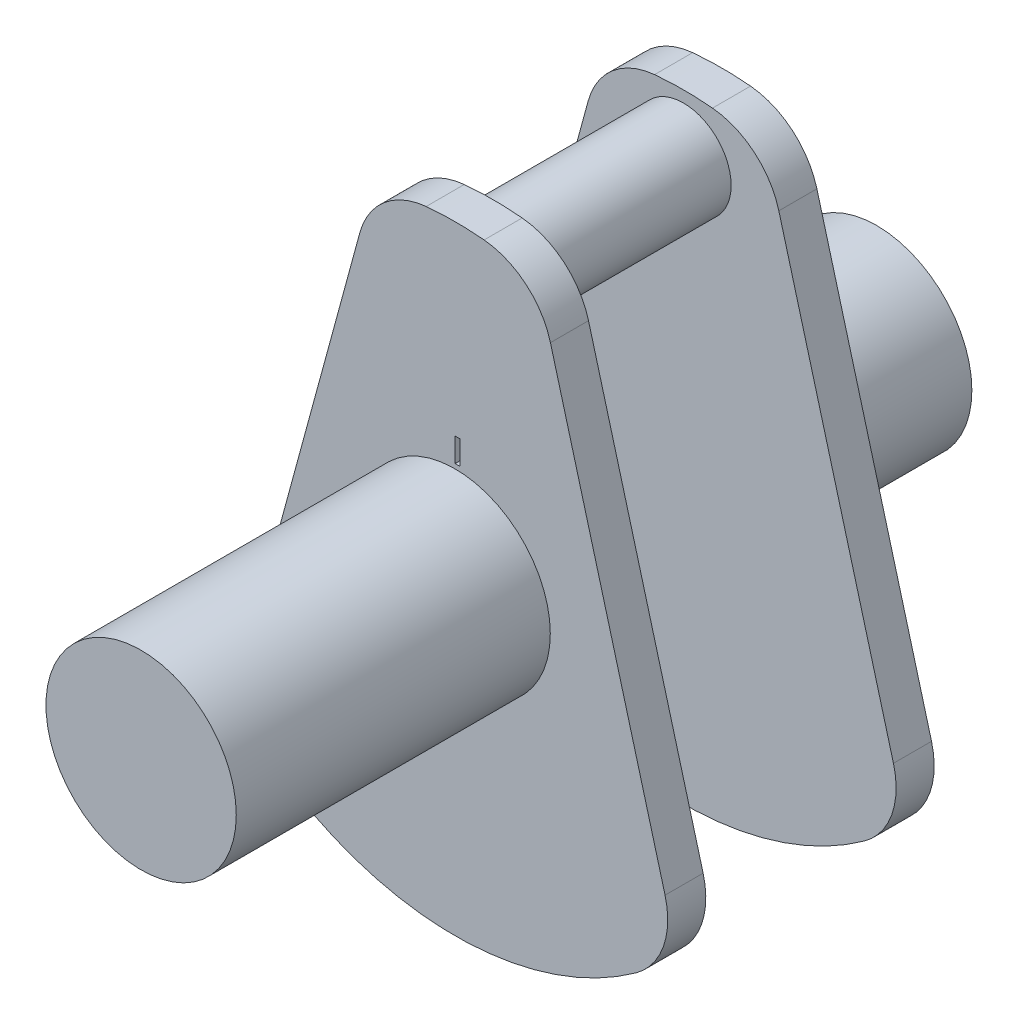
from build123d import *

# Parameters (mm, degrees)
BOSS_EXTRUDE1_DEPTH = 8
SKETCH2_R           = 10
BOSS_EXTRUDE2_DEPTH = 20
SKETCH3_R           = 20
BOSS_EXTRUDE3_DEPTH = 32.6
SKETCH4_R           = 20
BOSS_EXTRUDE4_DEPTH = 33.4
SCALE1_SCALE        = 0.1
SKETCH5_W           = 0.1
SKETCH5_H           = 0.5
CUT_EXTRUDE1_DEPTH  = 0.1


with BuildPart() as part:
    # Sketch1 → Boss-Extrude1 (new body)
    with BuildSketch(Plane.XY):
        with BuildLine():
            Line((-20.028432016, 52.986309253), (-44.118678612, -35.527865892))
            ThreePointArc((-44.118678612, -35.527865892), (-43.764838253, -45.063961124), (-38.045225076, -52.702569661))
            ThreePointArc((-38.045225076, -52.702569661), (0, -65), (38.045225076, -52.702569661))
            ThreePointArc((38.045225076, -52.702569661), (43.764838253, -45.063961124), (44.118678612, -35.527865892))
            Line((44.118678612, -35.527865892), (20.028432016, 52.986309253))
            ThreePointArc((20.028432016, 52.986309253), (14.890634236, 61.027786061), (6.08877551, 64.714193287))
            ThreePointArc((6.08877551, 64.714193287), (0, 65), (-6.08877551, 64.714193287))
            ThreePointArc((-6.08877551, 64.714193287), (-14.890634236, 61.027786061), (-20.028432016, 52.986309253))
        make_face()
    extrude(amount=BOSS_EXTRUDE1_DEPTH)

    # Sketch2 → Boss-Extrude2 (add)
    with BuildSketch(Plane.XY.offset(8)):
        with Locations((0, 52.59)):
            Circle(SKETCH2_R)
    extrude(amount=BOSS_EXTRUDE2_DEPTH)

    # Sketch3 → Boss-Extrude3 (add)
    with BuildSketch(Plane(origin=(0, 0, 0), x_dir=(-1, 0, 0), z_dir=(0, 0, -1))):
        Circle(SKETCH3_R)
    extrude(amount=BOSS_EXTRUDE3_DEPTH)

    # Mirror1: part across plane


with BuildPart() as part_1:
    add(part.part)
    add(part.part.mirror(Plane(origin=(0, 52.59, 28), x_dir=(1, 0, 0), z_dir=(0, 0, 1))))

    # Sketch4 → Boss-Extrude4 (add)
    with BuildSketch(Plane.XY.offset(88.6)):
        Circle(SKETCH4_R)
    extrude(amount=BOSS_EXTRUDE4_DEPTH)


with BuildPart() as part_2:
    # Scale1: scaled about (0, -1.216751814, 40.138857798)
    add(part_1.part.scale(SCALE1_SCALE).moved(Location((0, -1.095076633, 36.124972018))))

    # Sketch5 → Cut-Extrude1 (cut)
    with BuildSketch(Plane.XY.offset(41.724972018)):
        with Locations((0.05, 1.251745482)):
            Rectangle(SKETCH5_W, SKETCH5_H)
    extrude(amount=-CUT_EXTRUDE1_DEPTH, mode=Mode.SUBTRACT)


solid = part_2.part
